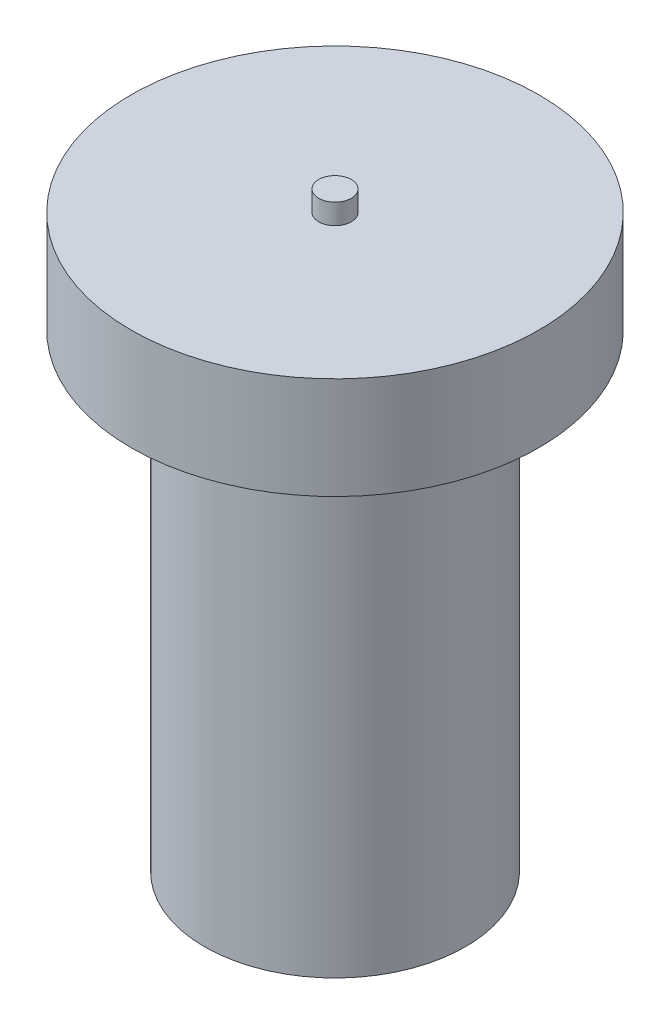
from build123d import *

# Parameters (mm, degrees)
SKETCH1_R           = 32
BOSS_EXTRUDE1_DEPTH = 110
SKETCH2_R           = 5
BOSS_EXTRUDE2_DEPTH = 5
SKETCH3_R           = 50
BOSS_EXTRUDE3_DEPTH = 25
SKETCH4_R           = 4
BOSS_EXTRUDE4_DEPTH = 5
SKETCH5_R           = 15
BOSS_EXTRUDE5_DEPTH = 4


with BuildPart() as part:
    # Sketch1 → Boss-Extrude1 (new body)
    with BuildSketch(Plane(origin=(0, 0, 0), x_dir=(1, 0, 0), z_dir=(0, 1, 0))):
        Circle(SKETCH1_R)
    extrude(amount=BOSS_EXTRUDE1_DEPTH)

    # Sketch2 → Boss-Extrude2 (add)
    with BuildSketch(Plane(origin=(0, 110, 0), x_dir=(1, 0, 0), z_dir=(0, 1, 0))):
        Circle(SKETCH2_R)
    extrude(amount=BOSS_EXTRUDE2_DEPTH)

    # Sketch3 → Boss-Extrude3 (add)
    with BuildSketch(Plane(origin=(0, 115, 0), x_dir=(1, 0, 0), z_dir=(0, 1, 0))):
        Circle(SKETCH3_R)
    extrude(amount=BOSS_EXTRUDE3_DEPTH)

    # Sketch4 → Boss-Extrude4 (add)
    with BuildSketch(Plane(origin=(0, 140, 0), x_dir=(1, 0, 0), z_dir=(0, 1, 0))):
        Circle(SKETCH4_R)
    extrude(amount=BOSS_EXTRUDE4_DEPTH)

    # Sketch5 → Boss-Extrude5 (add)
    with BuildSketch(Plane.XZ):
        Circle(SKETCH5_R)
    extrude(amount=BOSS_EXTRUDE5_DEPTH)


solid = part.part
